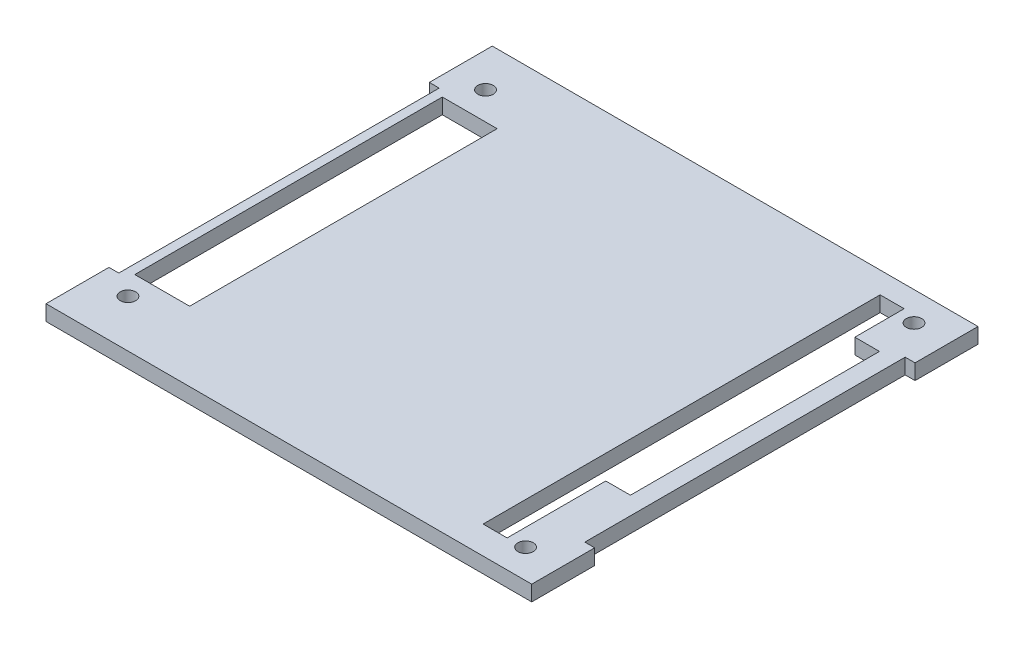
from build123d import *

# Parameters (mm, degrees)
BOSS_EXTRUDE1_DEPTH = 1.5875
SKETCH4_W           = 11.3
SKETCH4_H           = 63.35
SKETCH4_R           = 1.59
CUT_EXTRUDE2_DEPTH  = 3.175


with BuildPart() as part:
    # Sketch2 → Boss-Extrude1 (new body, symmetric)
    with BuildSketch(Plane(origin=(0, 0, 0), x_dir=(1, 0, 0), z_dir=(0, 1, 0))):
        Polygon((-50.03165, -32.99970686), (-52.06365, -32.99970686), (-52.06365, -45.96770686), (48.00035, -45.96770686), (48.00035, -32.99970686), (45.96835, -32.99970686), (45.96835, 33.00029314), (48.00035, 33.00029314), (48.00035, 45.96829314), (-52.06365, 45.96829314), (-52.06365, 33.00029314), (-50.03165, 33.00029314), align=None)
    extrude(amount=BOSS_EXTRUDE1_DEPTH, both=True)

    # Sketch4 → Cut-Extrude2 (cut)
    with BuildSketch(Plane(origin=(0, 1.5875, 0), x_dir=(1, 0, 0), z_dir=(0, 1, 0))):
        with Locations((-42.47165, 0.055)):
            Rectangle(SKETCH4_W, SKETCH4_H)
        with Locations((-44.95165, 37.465)):
            Circle(SKETCH4_R)
        Polygon((32.26835, -40.255), (37.21835, -40.255), (37.21835, -19.935), (42.29835, -19.935), (42.29835, 31.375), (37.21835, 31.375), (37.21835, 41.535), (32.26835, 41.535), align=None)
        with Locations((40.77835, -40.005)):
            Circle(SKETCH4_R)
        with Locations((40.77835, 40.005)):
            Circle(SKETCH4_R)
        with Locations((-44.95165, -36.195)):
            Circle(SKETCH4_R)
    extrude(amount=-CUT_EXTRUDE2_DEPTH, mode=Mode.SUBTRACT)


solid = part.part
